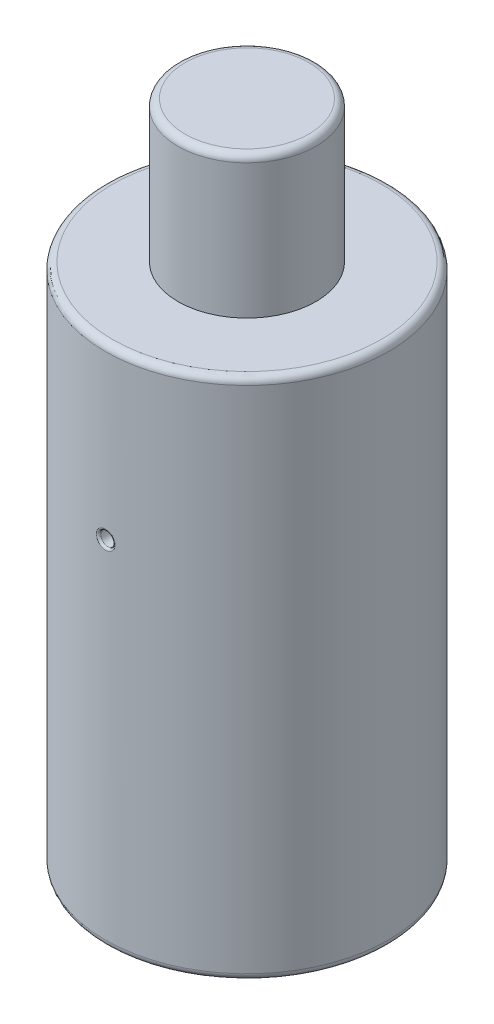
from build123d import *

# Parameters (mm, degrees)
SKETCH1_R               = 20
BOSS_EXTRUDE1_DEPTH     = 74
SKETCH2_R               = 9.75
BOSS_EXTRUDE2_DEPTH     = 20
FILLET1_R               = 1
CUT_EXTRUDE1_DEPTH      = 99.163129555
CUT_EXTRUDE1_DEPTH_BACK = 99.163129555
SKETCH3_R               = 1
SKETCH5_R               = 1
CUT_EXTRUDE2_DEPTH      = 99.163129577
FILLET2_R               = 0.3


with BuildPart() as part:
    # Sketch1 → Boss-Extrude1 (new body)
    with BuildSketch(Plane(origin=(0, 0, 0), x_dir=(1, 0, 0), z_dir=(0, 1, 0))):
        Circle(SKETCH1_R)
    extrude(amount=BOSS_EXTRUDE1_DEPTH)

    # Sketch2 → Boss-Extrude2 (add)
    with BuildSketch(Plane(origin=(0, 74, 0), x_dir=(1, 0, 0), z_dir=(0, 1, 0))):
        Circle(SKETCH2_R)
    extrude(amount=BOSS_EXTRUDE2_DEPTH)

    # Fillet1
    fillet1_edges = [part.edges().sort_by_distance(p)[0] for p in [
        (-20, 0, 0),
        (-20, 74, 0),
        (-9.75, 94, 0),
    ]]
    fillet(fillet1_edges, radius=FILLET1_R)

    # Sketch3 → Cut-Extrude1 (cut, two sides: drawn at the far end of the back side and taken through both)
    with BuildSketch(Plane.XY.offset(-CUT_EXTRUDE1_DEPTH_BACK)):
        with Locations((0, 50)):
            Circle(SKETCH3_R)
    extrude(amount=CUT_EXTRUDE1_DEPTH + CUT_EXTRUDE1_DEPTH_BACK, mode=Mode.SUBTRACT)

    # Sketch5 → Cut-Extrude2 (cut, through all)
    with BuildSketch(Plane(origin=(0, 0, 0), x_dir=(0, 0, -1), z_dir=(1, 0, 0))):
        with Locations((0, 20)):
            Circle(SKETCH5_R)
    extrude(amount=-CUT_EXTRUDE2_DEPTH, mode=Mode.SUBTRACT)

    # Fillet2
    fillet2_edges = [part.edges().sort_by_distance(p)[0] for p in [
        (-19.974984355, 20, 1),
        (-1, 50, -19.974984355),
        (-1.000000011, 49.999999999, 19.974984355),
    ]]
    fillet(fillet2_edges, radius=FILLET2_R)


solid = part.part
